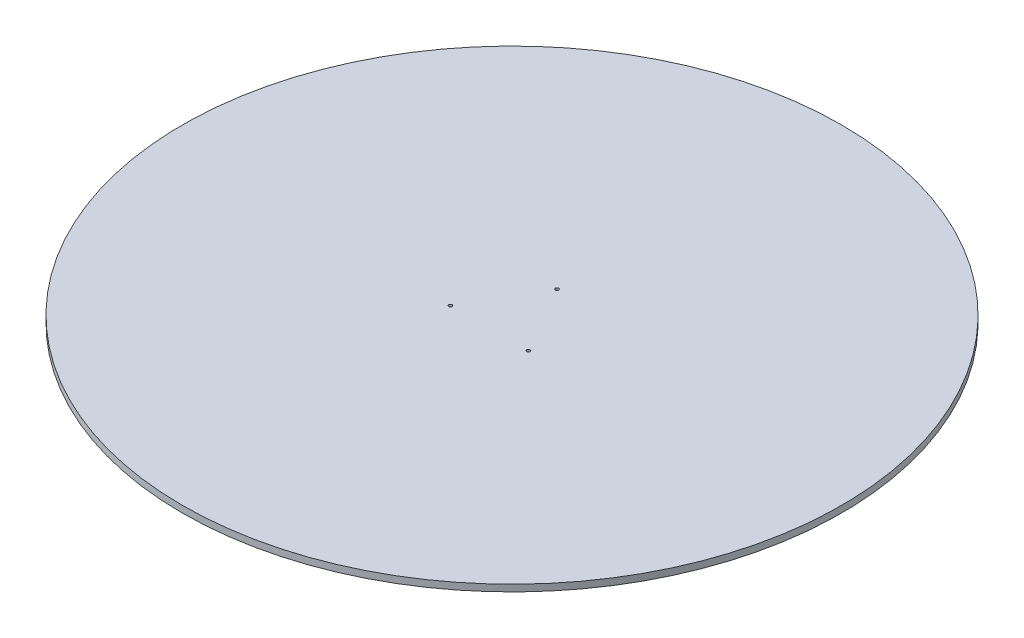
from build123d import *

# Parameters (mm, degrees)
SKETCH1_R           = 1250
SKETCH1_R_2         = 6.35
BOSS_EXTRUDE1_DEPTH = 25.4


with BuildPart() as part:
    # Sketch1 → Boss-Extrude1 (new body)
    with BuildSketch(Plane(origin=(0, 0, 0), x_dir=(1, 0, 0), z_dir=(0, 1, 0))):
        Circle(SKETCH1_R)
        with Locations((-147.989579257, -85.441823421)):
            Circle(SKETCH1_R_2, mode=Mode.SUBTRACT)
        with Locations((147.989579257, -85.441823421)):
            Circle(SKETCH1_R_2, mode=Mode.SUBTRACT)
        with Locations((0, 170.883646843)):
            Circle(SKETCH1_R_2, mode=Mode.SUBTRACT)
    extrude(amount=BOSS_EXTRUDE1_DEPTH)


solid = part.part
